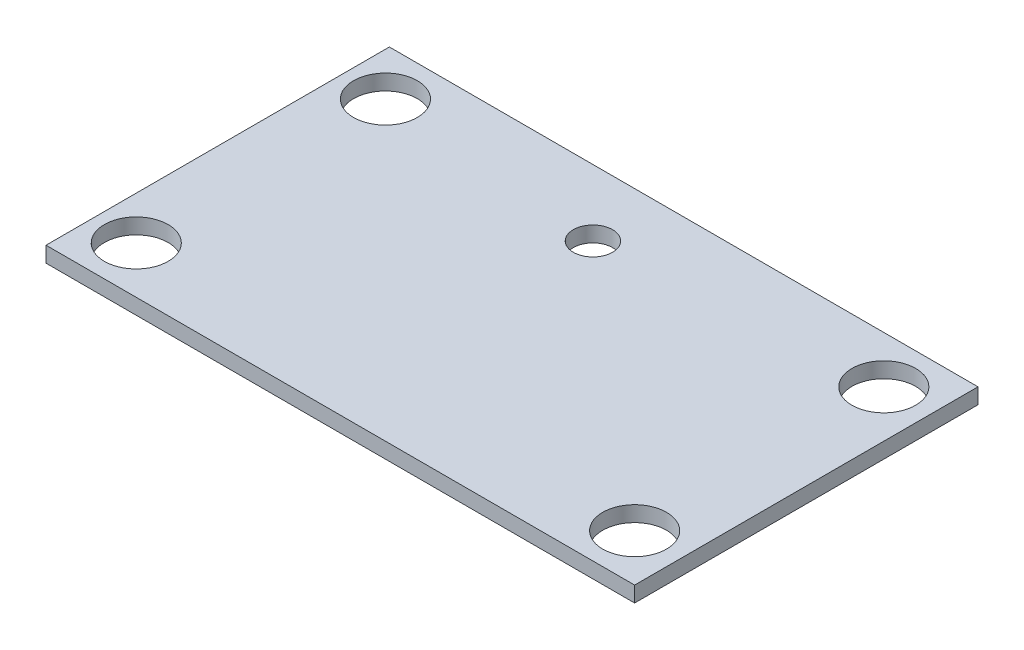
from build123d import *

# Parameters (mm, degrees)
SKETCH1_W           = 60
SKETCH1_H           = 35
SKETCH1_R           = 3.25
BOSS_EXTRUDE1_DEPTH = 1.5875
SKETCH2_R           = 2
CUT_EXTRUDE1_DEPTH  = 2.5875


with BuildPart() as part:
    # Sketch1 → Boss-Extrude1 (new body)
    with BuildSketch(Plane(origin=(0, 0, 0), x_dir=(1, 0, 0), z_dir=(0, 1, 0))):
        Rectangle(SKETCH1_W, SKETCH1_H)
        with Locations((-25.6, 12.7)):
            Circle(SKETCH1_R, mode=Mode.SUBTRACT)
        with Locations((25.2, 12.7)):
            Circle(SKETCH1_R, mode=Mode.SUBTRACT)
        with Locations((-25.6, -12.7)):
            Circle(SKETCH1_R, mode=Mode.SUBTRACT)
        with Locations((25.2, -12.7)):
            Circle(SKETCH1_R, mode=Mode.SUBTRACT)
    extrude(amount=BOSS_EXTRUDE1_DEPTH)

    # Sketch2 → Cut-Extrude1 (cut, through all)
    with BuildSketch(Plane(origin=(0, 1.5875, 0), x_dir=(1, 0, 0), z_dir=(0, 1, 0))):
        with Locations((-2.5, 10.75)):
            Circle(SKETCH2_R)
    extrude(amount=-CUT_EXTRUDE1_DEPTH, mode=Mode.SUBTRACT)


solid = part.part
